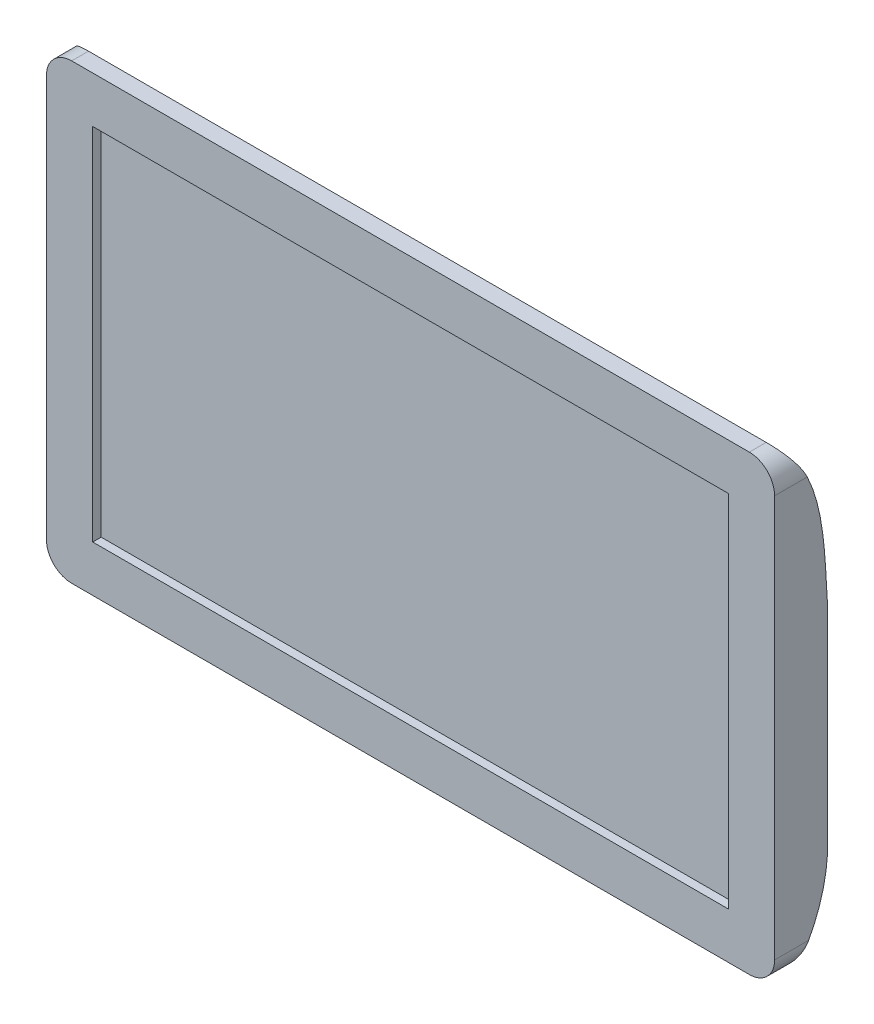
from build123d import *

# Parameters (mm, degrees)
BOSS_EXTRUDE1_DEPTH = 50.8
SKETCH2_W           = 479.425
SKETCH2_H           = 271.4625
CUT_EXTRUDE1_DEPTH  = 6.35
CUT_EXTRUDE2_DEPTH  = 762
SKETCH6_W           = 198.4375
SKETCH6_H           = 164.295373215
CUT_EXTRUDE3_DEPTH  = 10.922


with BuildPart() as part:
    # Sketch1 → Boss-Extrude1 (new body)
    with BuildSketch(Plane.XY):
        with BuildLine():
            Line((-255.5875, -170.65625), (255.5875, -170.65625))
            ThreePointArc((255.5875, -170.65625), (269.057884182, -165.076634182), (274.6375, -151.60625))
            Line((274.6375, -151.60625), (274.6375, 151.60625))
            ThreePointArc((274.6375, 151.60625), (269.057884182, 165.076634182), (255.5875, 170.65625))
            Line((255.5875, 170.65625), (-255.5875, 170.65625))
            ThreePointArc((-255.5875, 170.65625), (-269.057884182, 165.076634182), (-274.6375, 151.60625))
            Line((-274.6375, 151.60625), (-274.6375, -151.60625))
            ThreePointArc((-274.6375, -151.60625), (-269.057884182, -165.076634182), (-255.5875, -170.65625))
        make_face()
    extrude(amount=-BOSS_EXTRUDE1_DEPTH)

    # Sketch2 → Cut-Extrude1 (cut)
    with BuildSketch(Plane.XY):
        Rectangle(SKETCH2_W, SKETCH2_H)
    extrude(amount=-CUT_EXTRUDE1_DEPTH, mode=Mode.SUBTRACT)

    # Sketch4 → Cut-Extrude2 (cut)
    with BuildSketch(Plane(origin=(274.6375, 0, 0), x_dir=(0, 0, -1), z_dir=(1, 0, 0))):
        with BuildLine():
            Line((50.8, 151.60625), (24.619980511, 151.60625))
            add(Edge.make_bspline(
                [(24.619980511, 151.60625), (37.620188453, 124.390887767), (37.919518366, 93.154889178), (39.820271532, 62.244773812)],
                knots=[0.12550099, 0.12550099, 0.12550099, 0.12550099, 0.642402298, 0.642402298, 0.642402298, 0.642402298], degree=3))
            ThreePointArc((39.820271532, 62.244773812), (41.808148642, 58.008646197), (46.158299596, 56.284517648))
            Line((46.158299596, 56.284517648), (50.8, 56.284517648))
            Line((50.8, 56.284517648), (50.8, 151.60625))
        make_face()
        with BuildLine():
            Line((50.8, 170.65625), (12.7, 170.65625))
            add(Edge.make_bspline(
                [(12.7, 170.65625), (17.558504138, 164.584737247), (21.463596597, 158.21400058), (24.619980511, 151.60625)],
                knots=[0, 0, 0, 0, 0.12550099, 0.12550099, 0.12550099, 0.12550099], degree=3))
            Line((24.619980511, 151.60625), (50.8, 151.60625))
            Line((50.8, 151.60625), (50.8, 170.65625))
        make_face()
        with BuildLine():
            Line((50.8, -96.115482352), (50.8, -170.65625))
            Line((50.8, -170.65625), (12.7, -170.65625))
            add(Edge.make_bspline(
                [(12.7, -170.65625), (29.115546881, -150.814752865), (38.270494448, -127.771718295), (39.954605231, -102.050599403)],
                knots=[0, 0, 0, 0, 0.929133929, 0.929133929, 0.929133929, 0.929133929], degree=3))
            ThreePointArc((39.954605231, -102.050599403), (41.950070115, -97.830991726), (46.291037361, -96.115482352))
            Line((46.291037361, -96.115482352), (50.8, -96.115482352))
        make_face()
    extrude(amount=-CUT_EXTRUDE2_DEPTH, mode=Mode.SUBTRACT)

    # Sketch6 → Cut-Extrude3 (cut)
    with BuildSketch(Plane(origin=(0, 0, -50.8), x_dir=(-1, 0, 0), z_dir=(0, 0, -1))):
        with Locations((-175.41875, -19.902912796)):
            Rectangle(SKETCH6_W, SKETCH6_H)
        with Locations((175.41875, -19.902912796)):
            Rectangle(SKETCH6_W, SKETCH6_H)
    extrude(amount=-CUT_EXTRUDE3_DEPTH, mode=Mode.SUBTRACT)


solid = part.part
